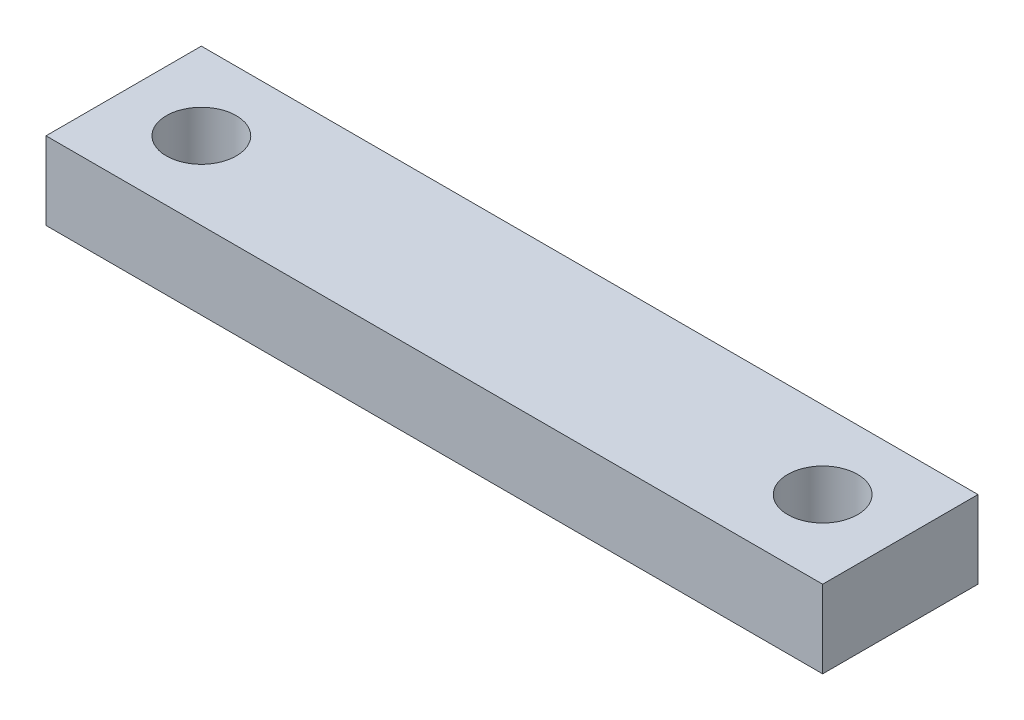
from build123d import *

# Parameters (mm, degrees)
SKETCH1_W           = 50
SKETCH1_H           = 10
SKETCH1_R           = 2.25
BOSS_EXTRUDE1_DEPTH = 5


with BuildPart() as part:
    # Sketch1 → Boss-Extrude1 (new body)
    with BuildSketch(Plane(origin=(0, 0, 0), x_dir=(1, 0, 0), z_dir=(0, 1, 0))):
        Rectangle(SKETCH1_W, SKETCH1_H)
        with Locations((-20, 0)):
            Circle(SKETCH1_R, mode=Mode.SUBTRACT)
        with Locations((20, 0)):
            Circle(SKETCH1_R, mode=Mode.SUBTRACT)
    extrude(amount=BOSS_EXTRUDE1_DEPTH)


solid = part.part
